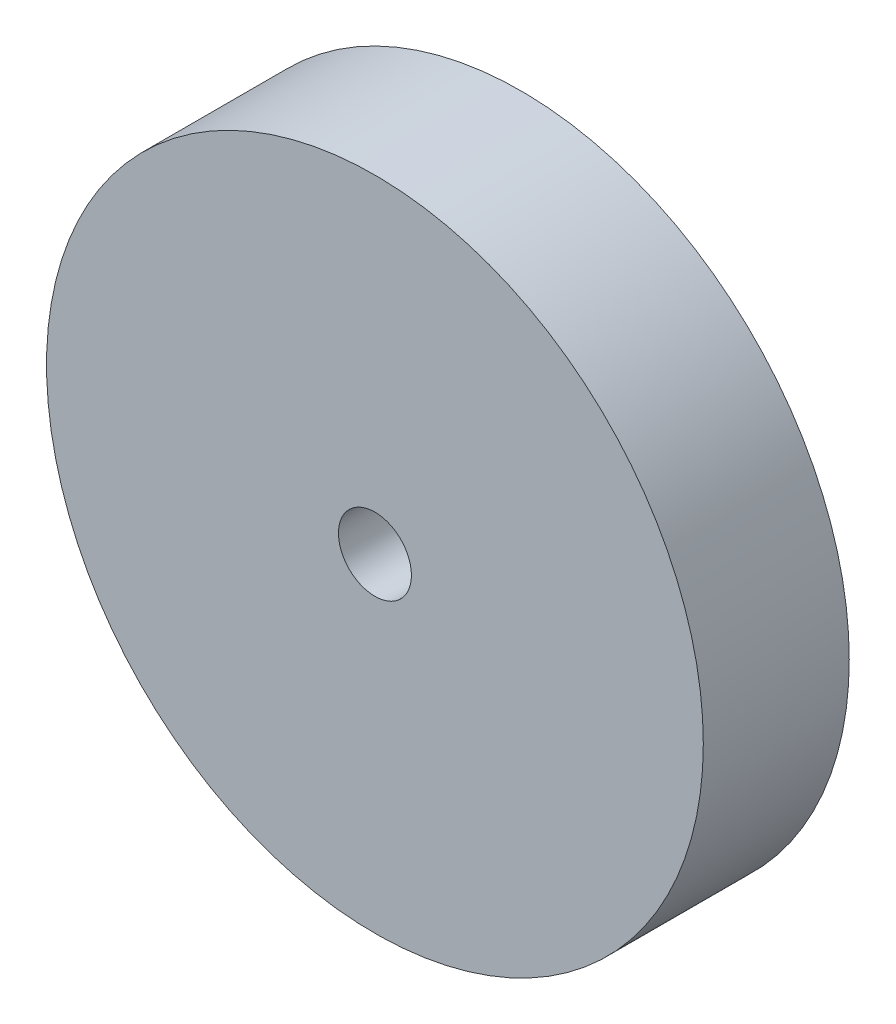
from build123d import *

# Parameters (mm, degrees)
SKETCH_1_R          = 9
EXTRUDE_1_DEPTH     = 4
SKETCH_2_R          = 1
CUT_EXTRUDE_1_DEPTH = 5


with BuildPart() as part:
    # 草图1 → 凸台-拉伸1 (new body)
    with BuildSketch(Plane.XY):
        Circle(SKETCH_1_R)
    extrude(amount=EXTRUDE_1_DEPTH)

    # 草图2 → 切除-拉伸1 (cut, through all)
    with BuildSketch(Plane.XY.offset(4)):
        Circle(SKETCH_2_R)
    extrude(amount=-CUT_EXTRUDE_1_DEPTH, mode=Mode.SUBTRACT)


solid = part.part
